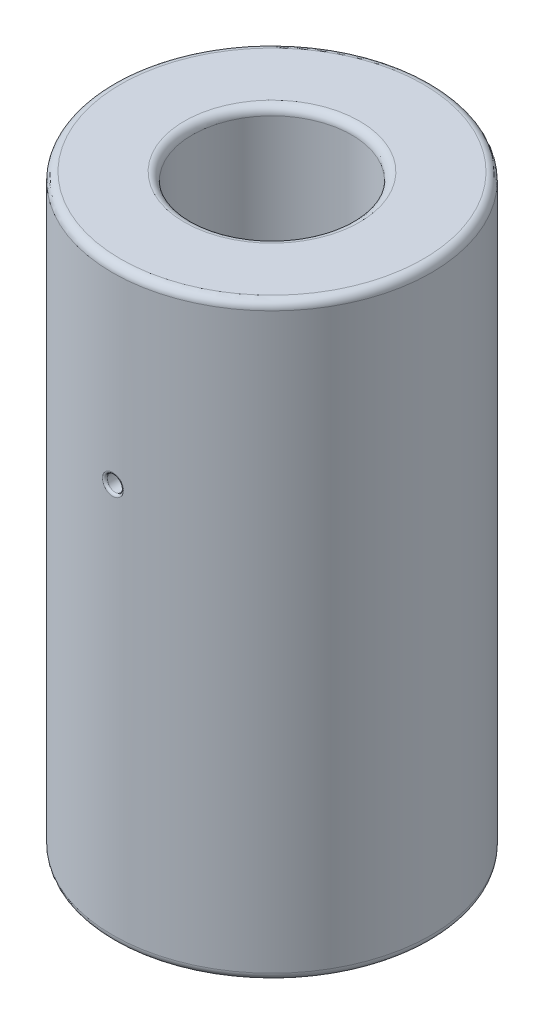
from build123d import *

# Parameters (mm, degrees)
SKETCH1_R               = 20
BOSS_EXTRUDE1_DEPTH     = 74
SKETCH2_R               = 10
CUT_EXTRUDE3_DEPTH      = 20
CUT_EXTRUDE1_DEPTH      = 80.221209281
CUT_EXTRUDE1_DEPTH_BACK = 80.221209281
SKETCH3_R               = 1
SKETCH5_R               = 1
CUT_EXTRUDE2_DEPTH      = 80.221209427
FILLET2_R               = 1
FILLET3_R               = 0.3


with BuildPart() as part:
    # Sketch1 → Boss-Extrude1 (new body)
    with BuildSketch(Plane(origin=(0, 0, 0), x_dir=(1, 0, 0), z_dir=(0, 1, 0))):
        Circle(SKETCH1_R)
    extrude(amount=BOSS_EXTRUDE1_DEPTH)

    # Sketch2 → Cut-Extrude3 (cut)
    with BuildSketch(Plane(origin=(0, 74, 0), x_dir=(1, 0, 0), z_dir=(0, 1, 0))):
        Circle(SKETCH2_R)
    extrude(amount=-CUT_EXTRUDE3_DEPTH, mode=Mode.SUBTRACT)

    # Sketch3 → Cut-Extrude1 (cut, two sides: drawn at the far end of the back side and taken through both)
    with BuildSketch(Plane.XY.offset(-CUT_EXTRUDE1_DEPTH_BACK)):
        with Locations((0, 50)):
            Circle(SKETCH3_R)
    extrude(amount=CUT_EXTRUDE1_DEPTH + CUT_EXTRUDE1_DEPTH_BACK, mode=Mode.SUBTRACT)

    # Sketch5 → Cut-Extrude2 (cut, through all)
    with BuildSketch(Plane(origin=(0, 0, 0), x_dir=(0, 0, -1), z_dir=(1, 0, 0))):
        with Locations((0, 20)):
            Circle(SKETCH5_R)
    extrude(amount=-CUT_EXTRUDE2_DEPTH, mode=Mode.SUBTRACT)

    # Fillet2
    fillet2_edges = [part.edges().sort_by_distance(p)[0] for p in [
        (-20, 0, 0),
        (-20, 74, 0),
        (-10, 74, 0),
        (-10, 54, 0),
    ]]
    fillet(fillet2_edges, radius=FILLET2_R)

    # Fillet3
    fillet3_edges = [part.edges().sort_by_distance(p)[0] for p in [
        (-1, 50, -19.974984355),
        (-1.000000011, 49.999999999, 19.974984355),
        (-19.974984355, 20, 1),
    ]]
    fillet(fillet3_edges, radius=FILLET3_R)


solid = part.part
